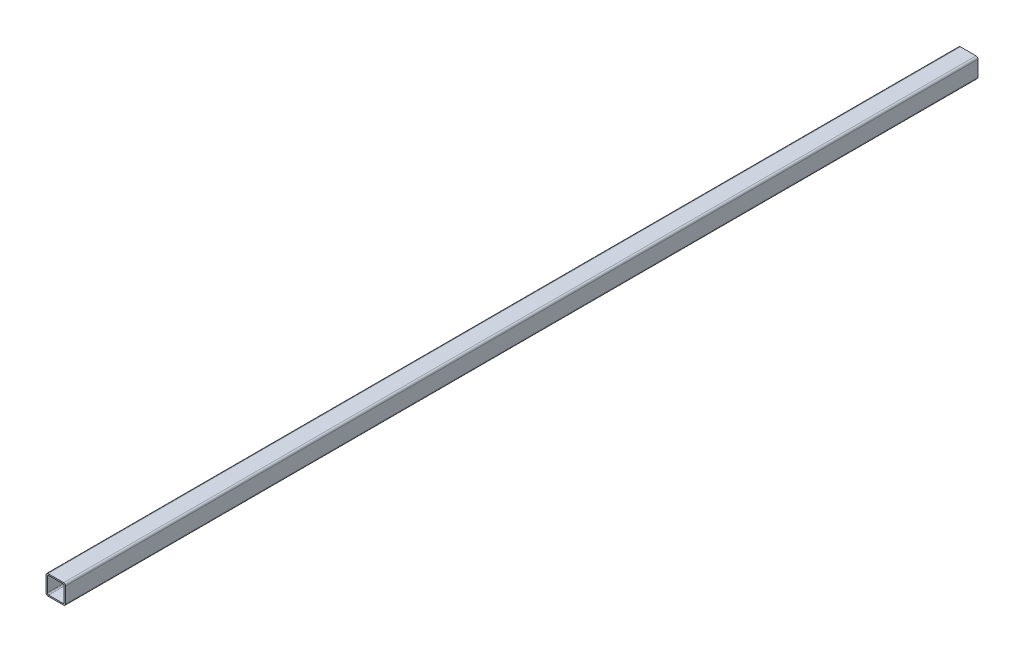
from build123d import *

# Parameters (mm, degrees)
EXTRUDE_1_DEPTH = 700


with BuildPart() as part:
    # Эскиз1 → Бобышка-Вытянуть1 (new body)
    with BuildSketch(Plane.XY):
        with BuildLine():
            Line((-25.388920969, 15), (-1.388920969, 15))
            ThreePointArc((-1.388920969, 15), (0.732399375, 14.121320344), (1.611079031, 12))
            Line((1.611079031, 12), (1.611079031, -12))
            ThreePointArc((1.611079031, -12), (0.732399375, -14.121320344), (-1.388920969, -15))
            Line((-1.388920969, -15), (-25.388920969, -15))
            ThreePointArc((-25.388920969, -15), (-27.510241313, -14.121320344), (-28.388920969, -12))
            Line((-28.388920969, -12), (-28.388920969, 12))
            ThreePointArc((-28.388920969, 12), (-27.510241313, 14.121320344), (-25.388920969, 15))
        make_face()
        with BuildLine():
            Line((-24.388920969, 13), (-2.388920969, 13))
            ThreePointArc((-2.388920969, 13), (-0.974707407, 12.414213562), (-0.388920969, 11))
            Line((-0.388920969, 11), (-0.388920969, -11))
            ThreePointArc((-0.388920969, -11), (-0.974707407, -12.414213562), (-2.388920969, -13))
            Line((-2.388920969, -13), (-24.388920969, -13))
            ThreePointArc((-24.388920969, -13), (-25.803134531, -12.414213562), (-26.388920969, -11))
            Line((-26.388920969, -11), (-26.388920969, 11))
            ThreePointArc((-26.388920969, 11), (-25.803134531, 12.414213562), (-24.388920969, 13))
        make_face(mode=Mode.SUBTRACT)
    extrude(amount=EXTRUDE_1_DEPTH)

    # Зеркальное отражение1: part across plane


with BuildPart() as part_1:
    add(part.part)
    add(part.part.mirror(Plane(origin=(-25.388920969, -12, 0), x_dir=(1, 0, 0), z_dir=(0, 0, 1))))


solid = part_1.part
